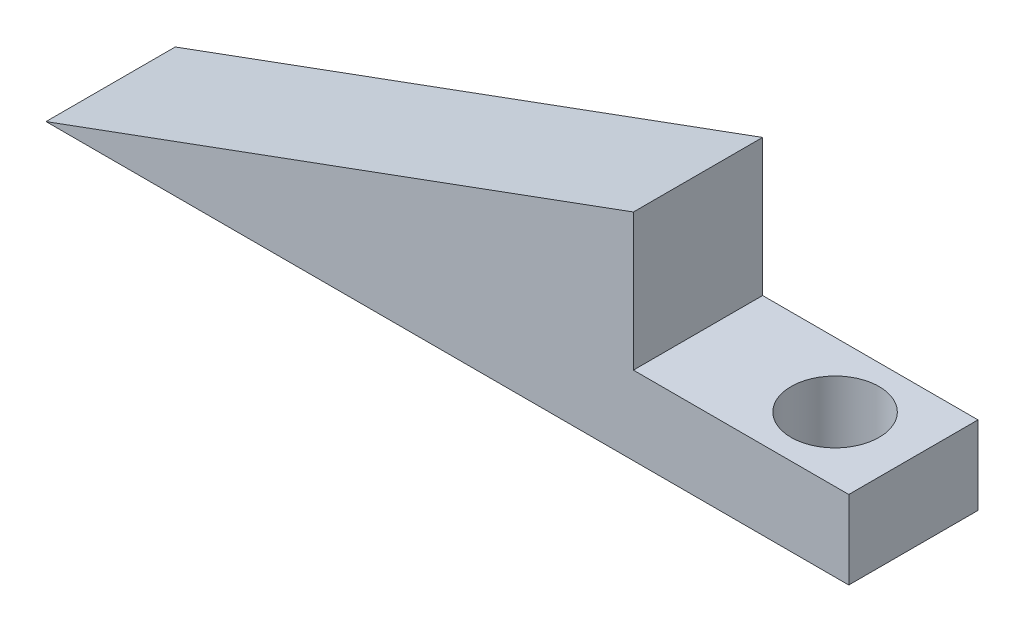
from build123d import *

# Parameters (mm, degrees)
BOSS_EXTRUDE1_DEPTH  = 6.6
SKETCH4_W            = 6.6
SKETCH4_H            = 4.006069052
BOSS_EXTRUDE2_DEPTH  = 11
M4_CLEARANCE_HOLE1_D = 4.5


with BuildPart() as part:
    # Sketch2 → Boss-Extrude1 (new body)
    with BuildSketch(Plane.XY):
        Polygon((-48.677836014, 4.833253272), (-48.677836014, -6.166746728), (-78.677836014, -6.166746728), align=None)
    extrude(amount=BOSS_EXTRUDE1_DEPTH)

    # Sketch4 → Boss-Extrude2 (add)
    with BuildSketch(Plane(origin=(-48.677836014, 0, 0), x_dir=(0, 0, -1), z_dir=(1, 0, 0))):
        with Locations((-3.3, -4.163712202)):
            Rectangle(SKETCH4_W, SKETCH4_H)
    extrude(amount=BOSS_EXTRUDE2_DEPTH)

    # M4 Clearance Hole1 (through all)
    with Locations(Plane(origin=(-41.677836014, -2.160677676, 3.3), x_dir=(0, 0, 1), z_dir=(0, 1, 0))):
        with Locations((0, 0)):
            Hole(M4_CLEARANCE_HOLE1_D / 2)


solid = part.part
